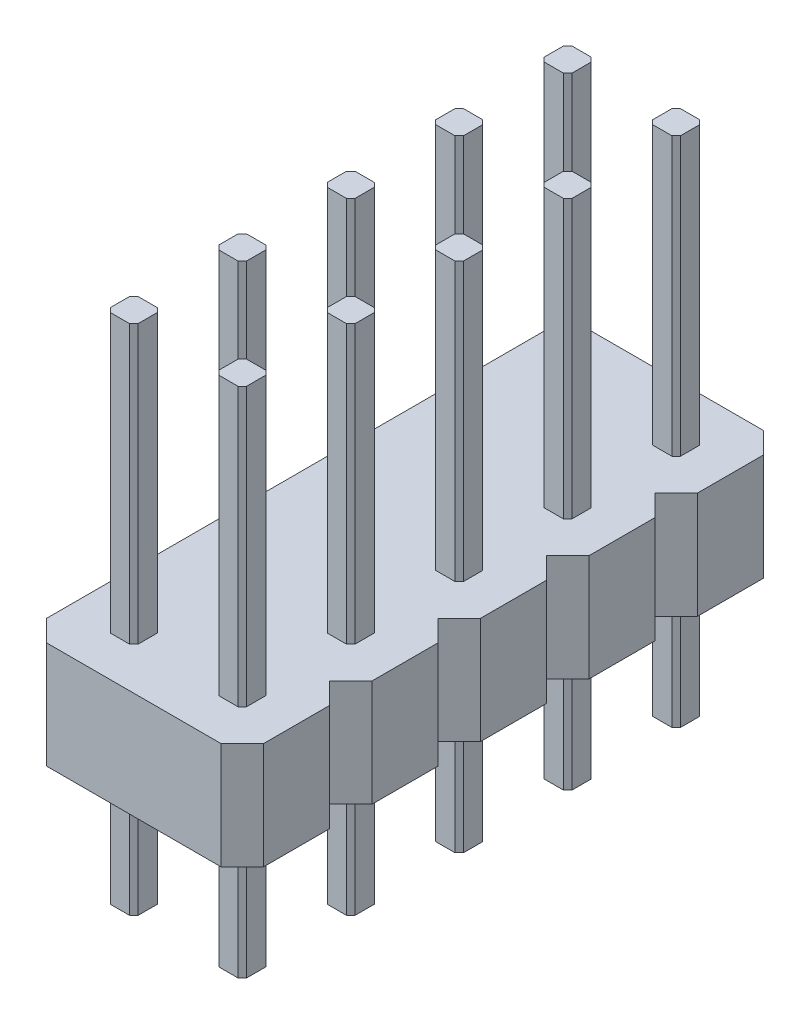
from build123d import *

# Parameters (mm, degrees)
BOSS_EXTRUDE1_DEPTH = 12
LPATTERN2_COUNT     = 2
LPATTERN2_PITCH     = 2.54
BOSS_EXTRUDE2_DEPTH = 2.5
LPATTERN3_COUNT     = 5
LPATTERN3_PITCH     = 2.54


with BuildPart() as part:
    # Sketch1 → Boss-Extrude1 (new body)
    with BuildSketch(Plane(origin=(0, 0, 0), x_dir=(1, 0, 0), z_dir=(0, 1, 0))):
        Polygon((-0.225, -0.325), (-0.325, -0.225), (-0.325, 0.225), (-0.225, 0.325), (0.225, 0.325), (0.325, 0.225), (0.325, -0.225), (0.225, -0.325), align=None)
    extrude(amount=BOSS_EXTRUDE1_DEPTH)


with BuildPart() as lpattern2_1:
    # LPattern2: pattern copy
    add(part.part.moved(Location(Vector(1, 0, 0) * (1 * LPATTERN2_PITCH))))


with BuildPart() as part_1:
    add(part.part)

    add(lpattern2_1.part)  # Boss-Extrude2 merges LPattern2_1
    # Sketch2 → Boss-Extrude2 (add)
    with BuildSketch(Plane(origin=(0, 3, 0), x_dir=(-1, 0, 0), z_dir=(0, -1, 0))):
        Polygon((-3.31, 1.27), (-3.81, 0.77), (-3.81, -0.77), (-3.31, -1.27), (0.77, -1.27), (1.27, -0.77), (1.27, 0.77), (0.77, 1.27), align=None)
    extrude(amount=-BOSS_EXTRUDE2_DEPTH)


with BuildPart() as lpattern3_1:
    # LPattern3: pattern copy
    add(part_1.part.moved(Location(Vector(0, 0, 1) * (1 * LPATTERN3_PITCH))))


with BuildPart() as lpattern3_2:
    # LPattern3: pattern copy
    add(part_1.part.moved(Location(Vector(0, 0, 1) * (2 * LPATTERN3_PITCH))))


with BuildPart() as lpattern3_3:
    # LPattern3: pattern copy
    add(part_1.part.moved(Location(Vector(0, 0, 1) * (3 * LPATTERN3_PITCH))))


with BuildPart() as lpattern3_4:
    # LPattern3: pattern copy
    add(part_1.part.moved(Location(Vector(0, 0, 1) * (4 * LPATTERN3_PITCH))))


with BuildPart() as part_2:
    add(part_1.part)

    # Combine1: union LPattern3_1, LPattern3_2, LPattern3_3, LPattern3_4
    add(lpattern3_1.part)
    add(lpattern3_2.part)
    add(lpattern3_3.part)
    add(lpattern3_4.part)


solid = part_2.part
